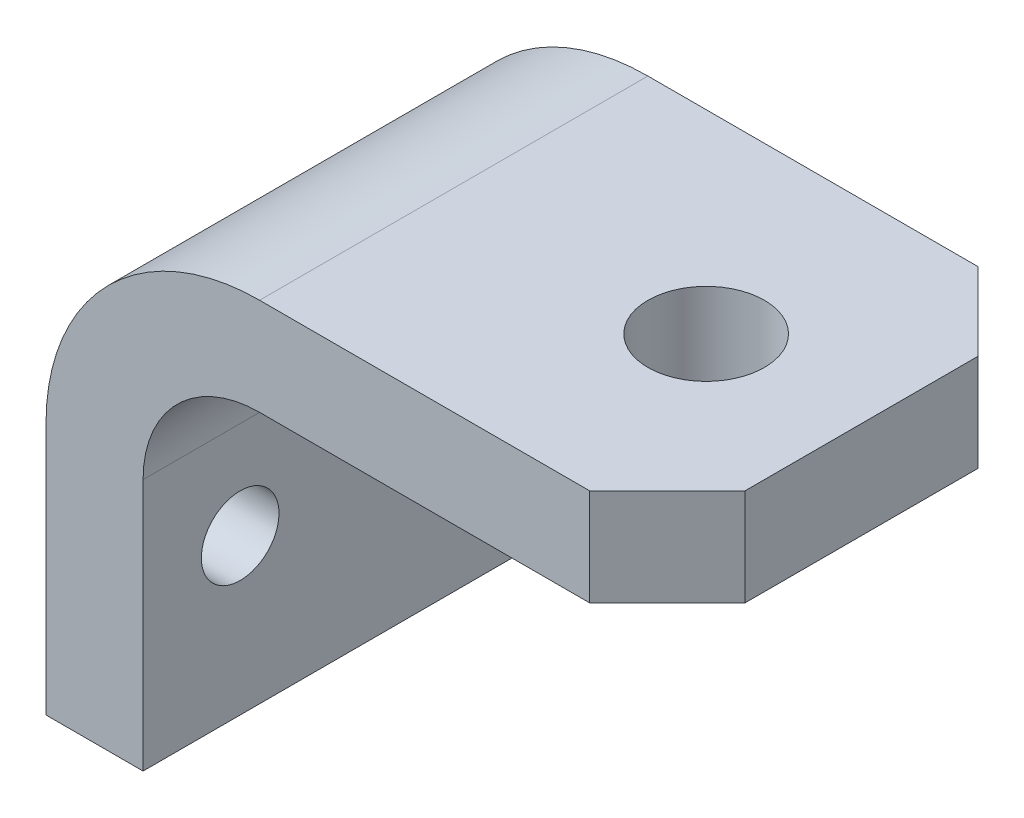
from build123d import *

# Parameters (mm, degrees)
HITCH_PROFILE_FOR_EXTRUSION_DEPTH = 31.75
SKETCH2_R                         = 9.525
BALL_ANCHOR_HOLE_DEPTH            = 77.2
F_45_DEG_CORNERS_DEPTH            = 77.2
BOLT_HOLE_X_2_REACH               = 17.875
SKETCH4_R                         = 6.35


with BuildPart() as part:
    # Sketch1 → Hitch Profile for Extrusion (new body, symmetric)
    with BuildSketch(Plane.XY):
        with BuildLine():
            Line((-76.2, -60.325), (-76.2, -19.05))
            ThreePointArc((-76.2, -19.05), (-65.970704333, 5.645704333), (-41.275, 15.875))
            Line((-41.275, 15.875), (25.4, 15.875))
            Line((25.4, 15.875), (25.4, 0))
            Line((25.4, 0), (-41.275, 0))
            ThreePointArc((-41.275, 0), (-54.745384182, -5.579615818), (-60.325, -19.05))
            Line((-60.325, -19.05), (-60.325, -60.325))
            Line((-60.325, -60.325), (-76.2, -60.325))
        make_face()
    extrude(amount=HITCH_PROFILE_FOR_EXTRUSION_DEPTH, both=True)

    # Sketch2 → Ball Anchor hole (cut, through all)
    with BuildSketch(Plane(origin=(0, 15.875, 0), x_dir=(1, 0, 0), z_dir=(0, 1, 0))):
        Circle(SKETCH2_R)
    extrude(amount=-BALL_ANCHOR_HOLE_DEPTH, mode=Mode.SUBTRACT)

    # Sketch3 → 45 Deg Corners (cut, through all)
    with BuildSketch(Plane(origin=(0, 15.875, 0), x_dir=(1, 0, 0), z_dir=(0, 1, 0))):
        Polygon((12.7, 31.75), (25.4, 19.05), (25.4, 31.75), align=None)
        Polygon((12.7, -31.75), (25.4, -19.05), (25.4, -31.75), align=None)
    extrude(amount=-F_45_DEG_CORNERS_DEPTH, mode=Mode.SUBTRACT)

    # Sketch4 → Bolt Hole x 2 (cut, up to next)
    with BuildSketch(Plane(origin=(-60.325, 0, 0), x_dir=(0, 0, -1), z_dir=(1, 0, 0)), mode=Mode.PRIVATE) as bolt_hole_x_2_sk1:
        with Locations((-15.875, -34.925)):
            Circle(SKETCH4_R)
    bolt_hole_x_2_tool1 = extrude(bolt_hole_x_2_sk1.sketch, amount=-BOLT_HOLE_X_2_REACH, mode=Mode.PRIVATE) & part.part
    add(bolt_hole_x_2_tool1.solids().sort_by_distance((-60.325, -34.925, 15.875))[0], mode=Mode.SUBTRACT)
    # Sketch4 → Bolt Hole x 2 (cut, up to next)
    with BuildSketch(Plane(origin=(-60.325, 0, 0), x_dir=(0, 0, -1), z_dir=(1, 0, 0)), mode=Mode.PRIVATE) as bolt_hole_x_2_sk2:
        with Locations((15.875, -34.925)):
            Circle(SKETCH4_R)
    bolt_hole_x_2_tool2 = extrude(bolt_hole_x_2_sk2.sketch, amount=-BOLT_HOLE_X_2_REACH, mode=Mode.PRIVATE) & part.part
    add(bolt_hole_x_2_tool2.solids().sort_by_distance((-60.325, -34.925, -15.875))[0], mode=Mode.SUBTRACT)


solid = part.part
